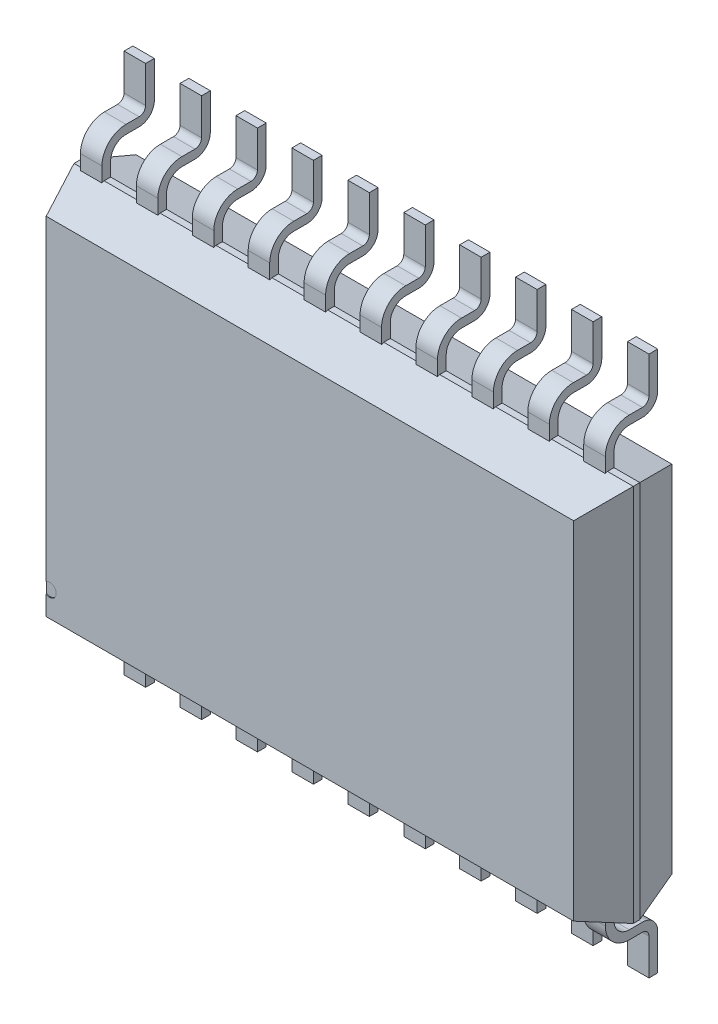
from build123d import *

# Parameters (mm, degrees)
SKETCH1_W                = 6.5
SKETCH1_H                = 4.4
BASE_EXTRUDE_DEPTH       = 1.0922
CHAMFER1_SIZE            = 0.508
CHAMFER1_SIZE2           = 0.184896879
CHAMFER1_PART_2_SIZE     = 0.508
CHAMFER1_PART_2_SIZE2    = 0.184896879
CHAMFER1_PART_3_SIZE     = 0.508
CHAMFER1_PART_3_SIZE2    = 0.184896879
CHAMFER1_PART_4_SIZE     = 0.508
CHAMFER1_PART_4_SIZE2    = 0.184896879
CHAMFER7_SIZE            = 0.508
CHAMFER7_SIZE2           = 0.13611819
CHAMFER7_PART_2_SIZE     = 0.508
CHAMFER7_PART_2_SIZE2    = 0.13611819
CHAMFER7_PART_3_SIZE     = 0.508
CHAMFER7_PART_3_SIZE2    = 0.13611819
CHAMFER7_PART_4_SIZE     = 0.508
CHAMFER7_PART_4_SIZE2    = 0.13611819
BOSS_EXTRUDE_THIN1_DEPTH = 0.125
LPATTERN1_COUNT          = 10
LPATTERN1_PITCH          = 0.65
MIRROR1_COPY_1_DEPTH     = 0.125
MIRROR1_COPY_2_DEPTH     = 0.125
MIRROR1_COPY_3_DEPTH     = 0.125
MIRROR1_COPY_4_DEPTH     = 0.125
MIRROR1_COPY_5_DEPTH     = 0.125
MIRROR1_COPY_6_DEPTH     = 0.125
MIRROR1_COPY_7_DEPTH     = 0.125
MIRROR1_COPY_8_DEPTH     = 0.125
MIRROR1_COPY_9_DEPTH     = 0.125
SKETCH3_R                = 0.076372661
EXTRUDE1_DEPTH           = 0.01


with BuildPart() as part:
    # Sketch1 → Base-Extrude (new body)
    with BuildSketch(Plane.XY):
        with Locations((3.025, 2.5175)):
            Rectangle(SKETCH1_W, SKETCH1_H)
    extrude(amount=BASE_EXTRUDE_DEPTH)

    # Chamfer1
    chamfer1_edges = [part.edges().sort_by_distance(p)[0] for p in [
        (6.275, 2.5175, 1.0922),
    ]]
    chamfer1_side = [part.faces().sort_by_distance(p)[0] for p in [
        (6.275, 2.5175, 0.5461),
    ]]
    chamfer(chamfer1_edges, length=CHAMFER1_SIZE, length2=CHAMFER1_SIZE2, reference=chamfer1_side[0])

    # Chamfer1 part 2
    chamfer1_part_2_edges = [part.edges().sort_by_distance(p)[0] for p in [
        (3.025, 4.7175, 1.0922),
    ]]
    chamfer1_part_2_side = [part.faces().sort_by_distance(p)[0] for p in [
        (3.025, 4.7175, 0.5461),
    ]]
    chamfer(chamfer1_part_2_edges, length=CHAMFER1_PART_2_SIZE, length2=CHAMFER1_PART_2_SIZE2, reference=chamfer1_part_2_side[0])

    # Chamfer1 part 3
    chamfer1_part_3_edges = [part.edges().sort_by_distance(p)[0] for p in [
        (-0.225, 2.5175, 1.0922),
    ]]
    chamfer1_part_3_side = [part.faces().sort_by_distance(p)[0] for p in [
        (-0.225, 2.5175, 0.5461),
    ]]
    chamfer(chamfer1_part_3_edges, length=CHAMFER1_PART_3_SIZE, length2=CHAMFER1_PART_3_SIZE2, reference=chamfer1_part_3_side[0])

    # Chamfer1 part 4
    chamfer1_part_4_edges = [part.edges().sort_by_distance(p)[0] for p in [
        (3.025, 0.3175, 1.0922),
    ]]
    chamfer1_part_4_side = [part.faces().sort_by_distance(p)[0] for p in [
        (3.025, 0.3175, 0.5461),
    ]]
    chamfer(chamfer1_part_4_edges, length=CHAMFER1_PART_4_SIZE, length2=CHAMFER1_PART_4_SIZE2, reference=chamfer1_part_4_side[0])

    # Chamfer7
    chamfer7_edges = [part.edges().sort_by_distance(p)[0] for p in [
        (3.025, 4.7175, 0),
    ]]
    chamfer7_side = [part.faces().sort_by_distance(p)[0] for p in [
        (3.025, 4.7175, 0.2921),
    ]]
    chamfer(chamfer7_edges, length=CHAMFER7_SIZE, length2=CHAMFER7_SIZE2, reference=chamfer7_side[0])

    # Chamfer7 part 2
    chamfer7_part_2_edges = [part.edges().sort_by_distance(p)[0] for p in [
        (6.275, 2.5175, 0),
    ]]
    chamfer7_part_2_side = [part.faces().sort_by_distance(p)[0] for p in [
        (6.275, 2.5175, 0.2921),
    ]]
    chamfer(chamfer7_part_2_edges, length=CHAMFER7_PART_2_SIZE, length2=CHAMFER7_PART_2_SIZE2, reference=chamfer7_part_2_side[0])

    # Chamfer7 part 3
    chamfer7_part_3_edges = [part.edges().sort_by_distance(p)[0] for p in [
        (3.025, 0.3175, 0),
    ]]
    chamfer7_part_3_side = [part.faces().sort_by_distance(p)[0] for p in [
        (3.025, 0.3175, 0.2921),
    ]]
    chamfer(chamfer7_part_3_edges, length=CHAMFER7_PART_3_SIZE, length2=CHAMFER7_PART_3_SIZE2, reference=chamfer7_part_3_side[0])

    # Chamfer7 part 4
    chamfer7_part_4_edges = [part.edges().sort_by_distance(p)[0] for p in [
        (-0.225, 2.5175, 0),
    ]]
    chamfer7_part_4_side = [part.faces().sort_by_distance(p)[0] for p in [
        (-0.225, 2.5175, 0.2921),
    ]]
    chamfer(chamfer7_part_4_edges, length=CHAMFER7_PART_4_SIZE, length2=CHAMFER7_PART_4_SIZE2, reference=chamfer7_part_4_side[0])

    # Sketch2 → Boss-Extrude-Thin1 (add, symmetric)
    with BuildSketch(Plane(origin=(0, 0, 0), x_dir=(0, 0, -1), z_dir=(1, 0, 0))):
        with BuildLine():
            Line((-0.508, 0.508), (-0.508, 0.1553))
            ThreePointArc((-0.508, 0.1553), (-0.455923586, 0.029576414), (-0.3302, -0.0225))
            Line((-0.3302, -0.0225), (-0.1778, -0.0225))
            ThreePointArc((-0.1778, -0.0225), (-0.052076414, -0.074576414), (0, -0.2003))
            Line((0, -0.2003), (0, -0.6225))
            Line((0, -0.6225), (-0.1016, -0.6225))
            Line((-0.1016, -0.6225), (-0.1016, -0.2003))
            ThreePointArc((-0.1016, -0.2003), (-0.123918463, -0.146418463), (-0.1778, -0.1241))
            Line((-0.1778, -0.1241), (-0.3302, -0.1241))
            ThreePointArc((-0.3302, -0.1241), (-0.527765635, -0.042265635), (-0.6096, 0.1553))
            Line((-0.6096, 0.1553), (-0.6096, 0.508))
            Line((-0.6096, 0.508), (-0.508, 0.508))
        make_face()
    boss_extrude_thin1 = extrude(amount=BOSS_EXTRUDE_THIN1_DEPTH, both=True)

    # LPattern1: Boss-Extrude-Thin1 ×10
    with Locations(*[(i * LPATTERN1_PITCH, 0, 0) for i in range(1, LPATTERN1_COUNT)]):
        add(boss_extrude_thin1)

    # Mirror1: Boss-Extrude-Thin1 across plane
    add(boss_extrude_thin1.mirror(Plane.ZX.offset(2.5175)))

    # Mirror1 copy 1 sketch → Mirror1 copy 1 (add, symmetric)
    with BuildSketch(Plane(origin=(0.65, 5.035, 0), x_dir=(0, 0, -1), z_dir=(1, 0, 0))):
        with BuildLine():
            Line((-0.508, -0.508), (-0.508, -0.1553))
            ThreePointArc((-0.508, -0.1553), (-0.455923586, -0.029576414), (-0.3302, 0.0225))
            Line((-0.3302, 0.0225), (-0.1778, 0.0225))
            ThreePointArc((-0.1778, 0.0225), (-0.052076414, 0.074576414), (0, 0.2003))
            Line((0, 0.2003), (0, 0.6225))
            Line((0, 0.6225), (-0.1016, 0.6225))
            Line((-0.1016, 0.6225), (-0.1016, 0.2003))
            ThreePointArc((-0.1016, 0.2003), (-0.123918463, 0.146418463), (-0.1778, 0.1241))
            Line((-0.1778, 0.1241), (-0.3302, 0.1241))
            ThreePointArc((-0.3302, 0.1241), (-0.527765635, 0.042265635), (-0.6096, -0.1553))
            Line((-0.6096, -0.1553), (-0.6096, -0.508))
            Line((-0.6096, -0.508), (-0.508, -0.508))
        make_face()
    extrude(amount=MIRROR1_COPY_1_DEPTH, both=True)

    # Mirror1 copy 2 sketch → Mirror1 copy 2 (add, symmetric)
    with BuildSketch(Plane(origin=(1.3, 5.035, 0), x_dir=(0, 0, -1), z_dir=(1, 0, 0))):
        with BuildLine():
            Line((-0.508, -0.508), (-0.508, -0.1553))
            ThreePointArc((-0.508, -0.1553), (-0.455923586, -0.029576414), (-0.3302, 0.0225))
            Line((-0.3302, 0.0225), (-0.1778, 0.0225))
            ThreePointArc((-0.1778, 0.0225), (-0.052076414, 0.074576414), (0, 0.2003))
            Line((0, 0.2003), (0, 0.6225))
            Line((0, 0.6225), (-0.1016, 0.6225))
            Line((-0.1016, 0.6225), (-0.1016, 0.2003))
            ThreePointArc((-0.1016, 0.2003), (-0.123918463, 0.146418463), (-0.1778, 0.1241))
            Line((-0.1778, 0.1241), (-0.3302, 0.1241))
            ThreePointArc((-0.3302, 0.1241), (-0.527765635, 0.042265635), (-0.6096, -0.1553))
            Line((-0.6096, -0.1553), (-0.6096, -0.508))
            Line((-0.6096, -0.508), (-0.508, -0.508))
        make_face()
    extrude(amount=MIRROR1_COPY_2_DEPTH, both=True)

    # Mirror1 copy 3 sketch → Mirror1 copy 3 (add, symmetric)
    with BuildSketch(Plane(origin=(1.95, 5.035, 0), x_dir=(0, 0, -1), z_dir=(1, 0, 0))):
        with BuildLine():
            Line((-0.508, -0.508), (-0.508, -0.1553))
            ThreePointArc((-0.508, -0.1553), (-0.455923586, -0.029576414), (-0.3302, 0.0225))
            Line((-0.3302, 0.0225), (-0.1778, 0.0225))
            ThreePointArc((-0.1778, 0.0225), (-0.052076414, 0.074576414), (0, 0.2003))
            Line((0, 0.2003), (0, 0.6225))
            Line((0, 0.6225), (-0.1016, 0.6225))
            Line((-0.1016, 0.6225), (-0.1016, 0.2003))
            ThreePointArc((-0.1016, 0.2003), (-0.123918463, 0.146418463), (-0.1778, 0.1241))
            Line((-0.1778, 0.1241), (-0.3302, 0.1241))
            ThreePointArc((-0.3302, 0.1241), (-0.527765635, 0.042265635), (-0.6096, -0.1553))
            Line((-0.6096, -0.1553), (-0.6096, -0.508))
            Line((-0.6096, -0.508), (-0.508, -0.508))
        make_face()
    extrude(amount=MIRROR1_COPY_3_DEPTH, both=True)

    # Mirror1 copy 4 sketch → Mirror1 copy 4 (add, symmetric)
    with BuildSketch(Plane(origin=(2.6, 5.035, 0), x_dir=(0, 0, -1), z_dir=(1, 0, 0))):
        with BuildLine():
            Line((-0.508, -0.508), (-0.508, -0.1553))
            ThreePointArc((-0.508, -0.1553), (-0.455923586, -0.029576414), (-0.3302, 0.0225))
            Line((-0.3302, 0.0225), (-0.1778, 0.0225))
            ThreePointArc((-0.1778, 0.0225), (-0.052076414, 0.074576414), (0, 0.2003))
            Line((0, 0.2003), (0, 0.6225))
            Line((0, 0.6225), (-0.1016, 0.6225))
            Line((-0.1016, 0.6225), (-0.1016, 0.2003))
            ThreePointArc((-0.1016, 0.2003), (-0.123918463, 0.146418463), (-0.1778, 0.1241))
            Line((-0.1778, 0.1241), (-0.3302, 0.1241))
            ThreePointArc((-0.3302, 0.1241), (-0.527765635, 0.042265635), (-0.6096, -0.1553))
            Line((-0.6096, -0.1553), (-0.6096, -0.508))
            Line((-0.6096, -0.508), (-0.508, -0.508))
        make_face()
    extrude(amount=MIRROR1_COPY_4_DEPTH, both=True)

    # Mirror1 copy 5 sketch → Mirror1 copy 5 (add, symmetric)
    with BuildSketch(Plane(origin=(3.25, 5.035, 0), x_dir=(0, 0, -1), z_dir=(1, 0, 0))):
        with BuildLine():
            Line((-0.508, -0.508), (-0.508, -0.1553))
            ThreePointArc((-0.508, -0.1553), (-0.455923586, -0.029576414), (-0.3302, 0.0225))
            Line((-0.3302, 0.0225), (-0.1778, 0.0225))
            ThreePointArc((-0.1778, 0.0225), (-0.052076414, 0.074576414), (0, 0.2003))
            Line((0, 0.2003), (0, 0.6225))
            Line((0, 0.6225), (-0.1016, 0.6225))
            Line((-0.1016, 0.6225), (-0.1016, 0.2003))
            ThreePointArc((-0.1016, 0.2003), (-0.123918463, 0.146418463), (-0.1778, 0.1241))
            Line((-0.1778, 0.1241), (-0.3302, 0.1241))
            ThreePointArc((-0.3302, 0.1241), (-0.527765635, 0.042265635), (-0.6096, -0.1553))
            Line((-0.6096, -0.1553), (-0.6096, -0.508))
            Line((-0.6096, -0.508), (-0.508, -0.508))
        make_face()
    extrude(amount=MIRROR1_COPY_5_DEPTH, both=True)

    # Mirror1 copy 6 sketch → Mirror1 copy 6 (add, symmetric)
    with BuildSketch(Plane(origin=(3.9, 5.035, 0), x_dir=(0, 0, -1), z_dir=(1, 0, 0))):
        with BuildLine():
            Line((-0.508, -0.508), (-0.508, -0.1553))
            ThreePointArc((-0.508, -0.1553), (-0.455923586, -0.029576414), (-0.3302, 0.0225))
            Line((-0.3302, 0.0225), (-0.1778, 0.0225))
            ThreePointArc((-0.1778, 0.0225), (-0.052076414, 0.074576414), (0, 0.2003))
            Line((0, 0.2003), (0, 0.6225))
            Line((0, 0.6225), (-0.1016, 0.6225))
            Line((-0.1016, 0.6225), (-0.1016, 0.2003))
            ThreePointArc((-0.1016, 0.2003), (-0.123918463, 0.146418463), (-0.1778, 0.1241))
            Line((-0.1778, 0.1241), (-0.3302, 0.1241))
            ThreePointArc((-0.3302, 0.1241), (-0.527765635, 0.042265635), (-0.6096, -0.1553))
            Line((-0.6096, -0.1553), (-0.6096, -0.508))
            Line((-0.6096, -0.508), (-0.508, -0.508))
        make_face()
    extrude(amount=MIRROR1_COPY_6_DEPTH, both=True)

    # Mirror1 copy 7 sketch → Mirror1 copy 7 (add, symmetric)
    with BuildSketch(Plane(origin=(4.55, 5.035, 0), x_dir=(0, 0, -1), z_dir=(1, 0, 0))):
        with BuildLine():
            Line((-0.508, -0.508), (-0.508, -0.1553))
            ThreePointArc((-0.508, -0.1553), (-0.455923586, -0.029576414), (-0.3302, 0.0225))
            Line((-0.3302, 0.0225), (-0.1778, 0.0225))
            ThreePointArc((-0.1778, 0.0225), (-0.052076414, 0.074576414), (0, 0.2003))
            Line((0, 0.2003), (0, 0.6225))
            Line((0, 0.6225), (-0.1016, 0.6225))
            Line((-0.1016, 0.6225), (-0.1016, 0.2003))
            ThreePointArc((-0.1016, 0.2003), (-0.123918463, 0.146418463), (-0.1778, 0.1241))
            Line((-0.1778, 0.1241), (-0.3302, 0.1241))
            ThreePointArc((-0.3302, 0.1241), (-0.527765635, 0.042265635), (-0.6096, -0.1553))
            Line((-0.6096, -0.1553), (-0.6096, -0.508))
            Line((-0.6096, -0.508), (-0.508, -0.508))
        make_face()
    extrude(amount=MIRROR1_COPY_7_DEPTH, both=True)

    # Mirror1 copy 8 sketch → Mirror1 copy 8 (add, symmetric)
    with BuildSketch(Plane(origin=(5.2, 5.035, 0), x_dir=(0, 0, -1), z_dir=(1, 0, 0))):
        with BuildLine():
            Line((-0.508, -0.508), (-0.508, -0.1553))
            ThreePointArc((-0.508, -0.1553), (-0.455923586, -0.029576414), (-0.3302, 0.0225))
            Line((-0.3302, 0.0225), (-0.1778, 0.0225))
            ThreePointArc((-0.1778, 0.0225), (-0.052076414, 0.074576414), (0, 0.2003))
            Line((0, 0.2003), (0, 0.6225))
            Line((0, 0.6225), (-0.1016, 0.6225))
            Line((-0.1016, 0.6225), (-0.1016, 0.2003))
            ThreePointArc((-0.1016, 0.2003), (-0.123918463, 0.146418463), (-0.1778, 0.1241))
            Line((-0.1778, 0.1241), (-0.3302, 0.1241))
            ThreePointArc((-0.3302, 0.1241), (-0.527765635, 0.042265635), (-0.6096, -0.1553))
            Line((-0.6096, -0.1553), (-0.6096, -0.508))
            Line((-0.6096, -0.508), (-0.508, -0.508))
        make_face()
    extrude(amount=MIRROR1_COPY_8_DEPTH, both=True)

    # Mirror1 copy 9 sketch → Mirror1 copy 9 (add, symmetric)
    with BuildSketch(Plane(origin=(5.85, 5.035, 0), x_dir=(0, 0, -1), z_dir=(1, 0, 0))):
        with BuildLine():
            Line((-0.508, -0.508), (-0.508, -0.1553))
            ThreePointArc((-0.508, -0.1553), (-0.455923586, -0.029576414), (-0.3302, 0.0225))
            Line((-0.3302, 0.0225), (-0.1778, 0.0225))
            ThreePointArc((-0.1778, 0.0225), (-0.052076414, 0.074576414), (0, 0.2003))
            Line((0, 0.2003), (0, 0.6225))
            Line((0, 0.6225), (-0.1016, 0.6225))
            Line((-0.1016, 0.6225), (-0.1016, 0.2003))
            ThreePointArc((-0.1016, 0.2003), (-0.123918463, 0.146418463), (-0.1778, 0.1241))
            Line((-0.1778, 0.1241), (-0.3302, 0.1241))
            ThreePointArc((-0.3302, 0.1241), (-0.527765635, 0.042265635), (-0.6096, -0.1553))
            Line((-0.6096, -0.1553), (-0.6096, -0.508))
            Line((-0.6096, -0.508), (-0.508, -0.508))
        make_face()
    extrude(amount=MIRROR1_COPY_9_DEPTH, both=True)

    # Sketch3 → Extrude1 (cut)
    with BuildSketch(Plane.XY.offset(1.0922)):
        with Locations((0, 0.792967363)):
            Circle(SKETCH3_R)
    extrude(amount=-EXTRUDE1_DEPTH, mode=Mode.SUBTRACT)


solid = part.part
